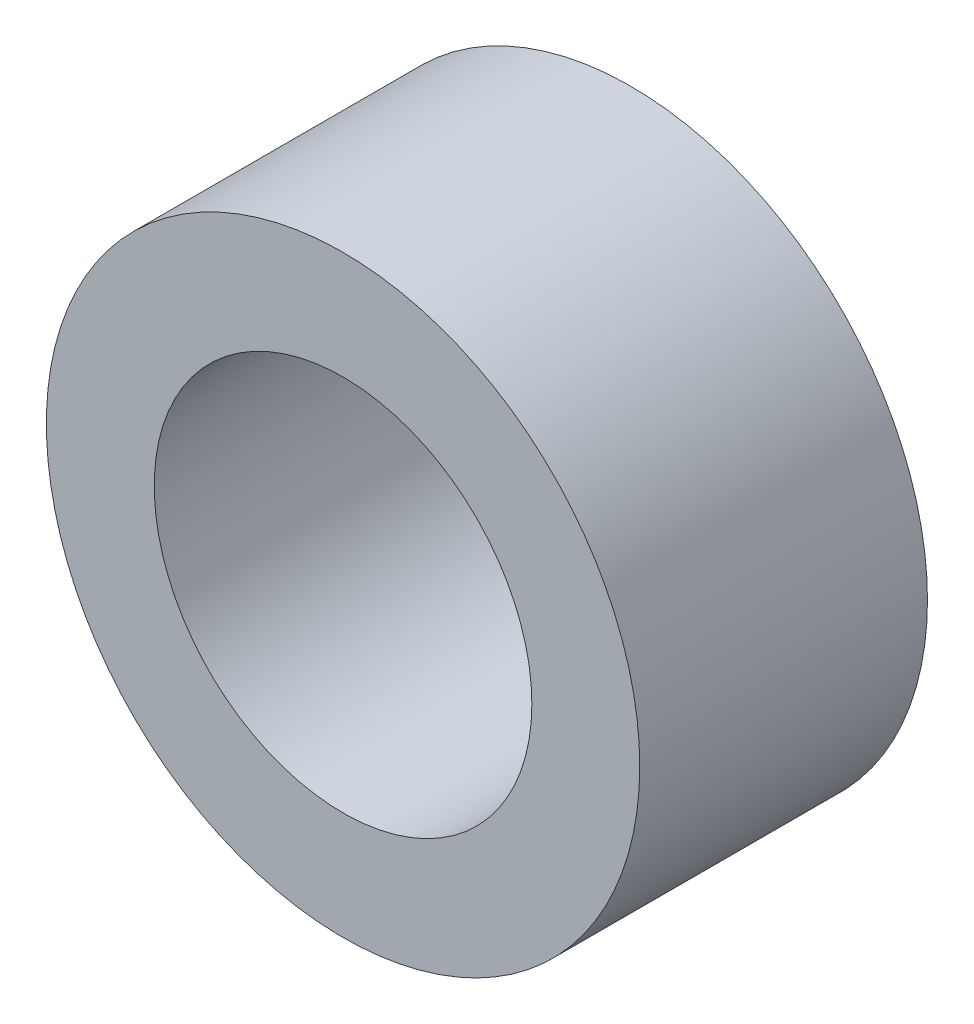
from build123d import *

# Parameters (mm, degrees)
SKETCH1_R           = 8.25
SKETCH1_R_2         = 5.25
BOSS_EXTRUDE1_DEPTH = 8


with BuildPart() as part:
    # Sketch1 → Boss-Extrude1 (new body)
    with BuildSketch(Plane.XY):
        Circle(SKETCH1_R)
        Circle(SKETCH1_R_2, mode=Mode.SUBTRACT)
    extrude(amount=BOSS_EXTRUDE1_DEPTH)


solid = part.part
